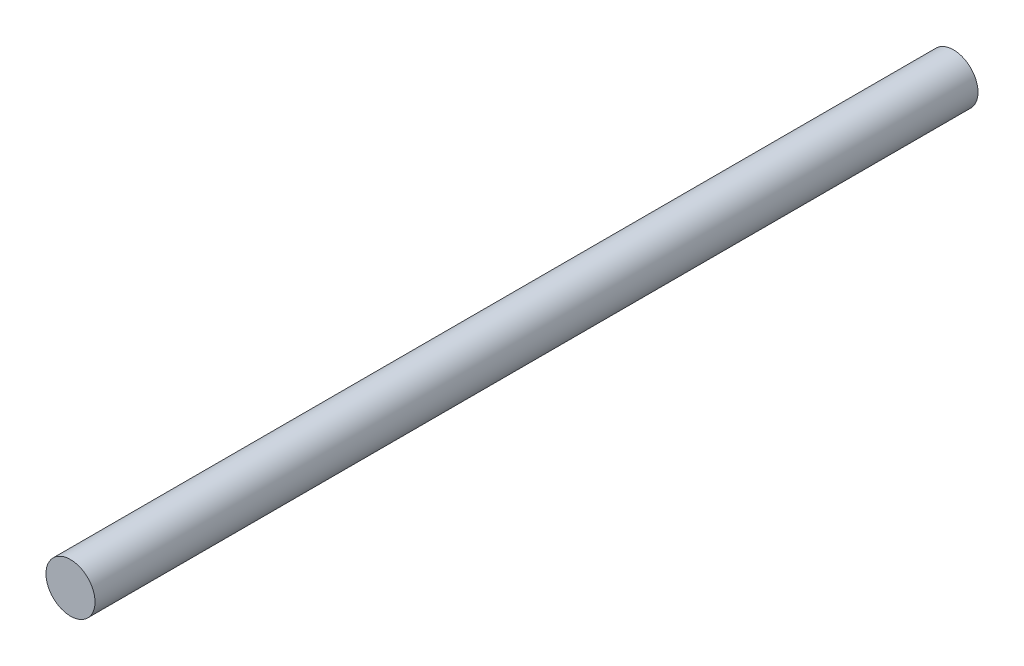
from build123d import *

# Parameters (mm, degrees)
SKETCH3_R                = 3.175
BOSS_EXTRUDE1_DEPTH      = 57.15
BOSS_EXTRUDE1_DEPTH_BACK = 57.15


with BuildPart() as part:
    # Sketch3 → Boss-Extrude1 (new body, two sides)
    with BuildSketch(Plane.XY) as boss_extrude1_sk:
        Circle(SKETCH3_R)
    extrude(amount=BOSS_EXTRUDE1_DEPTH)
    extrude(boss_extrude1_sk.sketch, amount=-BOSS_EXTRUDE1_DEPTH_BACK)


solid = part.part
